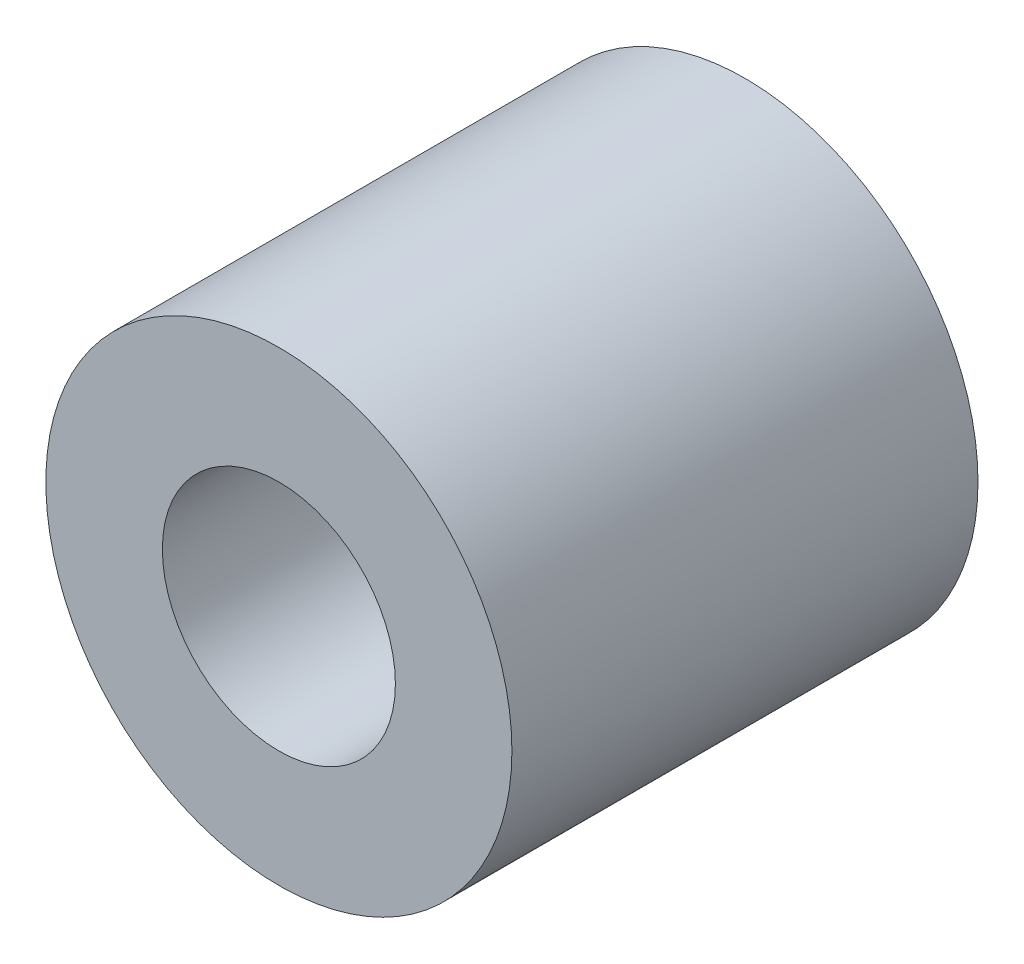
from build123d import *

# Parameters (mm, degrees)
SKETCH_1_R      = 6
SKETCH_1_R_2    = 3
EXTRUDE_1_DEPTH = 12


with BuildPart() as part:
    # 草图1 → 凸台-拉伸1 (new body)
    with BuildSketch(Plane.XY):
        Circle(SKETCH_1_R)
        Circle(SKETCH_1_R_2, mode=Mode.SUBTRACT)
    extrude(amount=EXTRUDE_1_DEPTH)


solid = part.part
